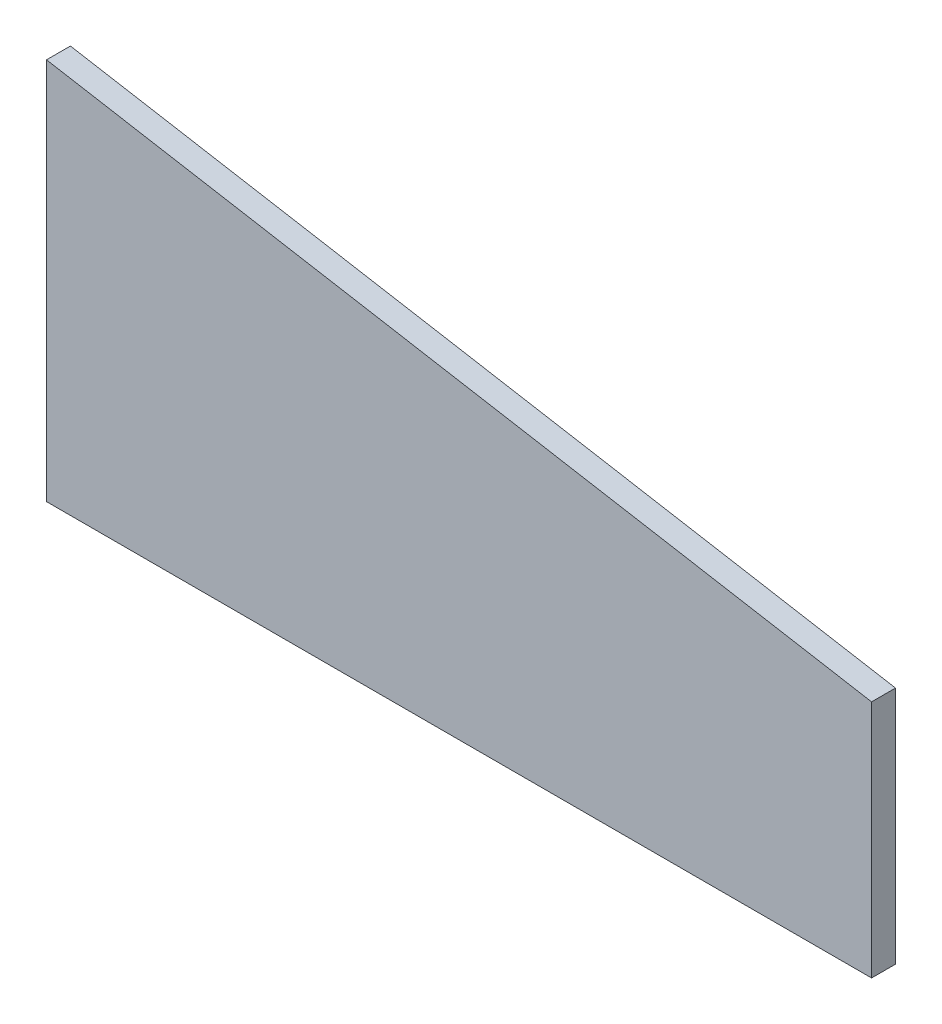
from build123d import *

# Parameters (mm, degrees)
BOSS_EXTRUDE1_DEPTH = 6.35


with BuildPart() as part:
    # Sketch1 → Boss-Extrude1 (new body)
    with BuildSketch(Plane.XY):
        Polygon((0, 0), (0, 101.6), (219.075, 63.5), (219.075, 0), align=None)
    extrude(amount=BOSS_EXTRUDE1_DEPTH)


solid = part.part
